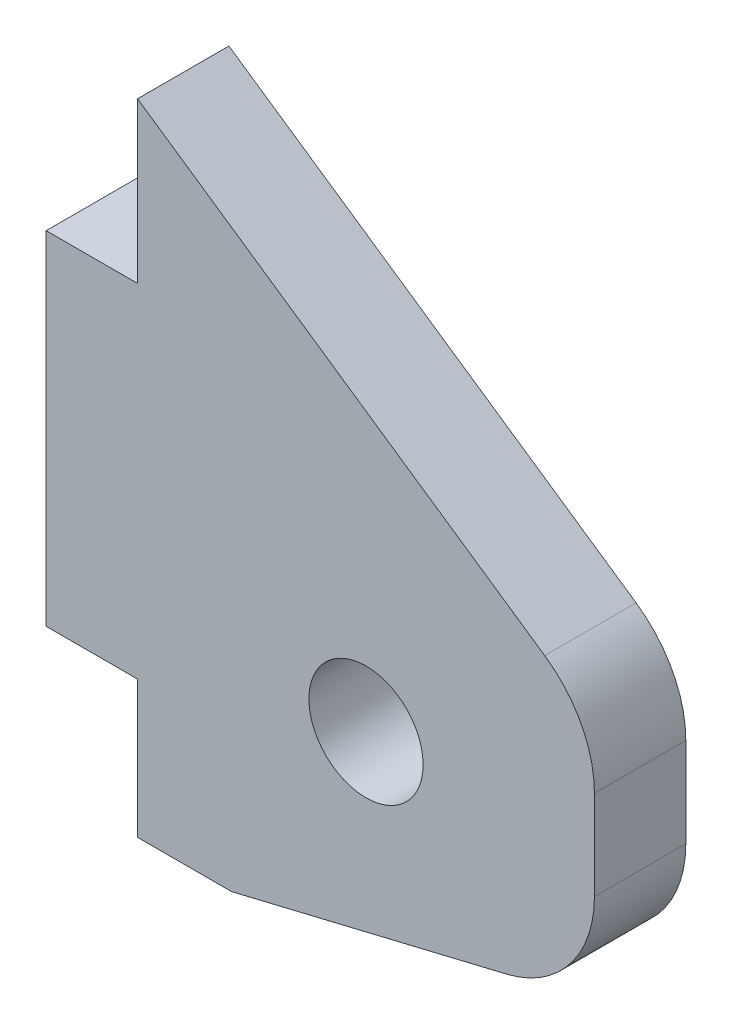
from build123d import *

# Parameters (mm, degrees)
SKETCH_1_R      = 2.5
EXTRUDE_1_DEPTH = 4
FILLET_1_R      = 5


with BuildPart() as part:
    # ｽｹｯﾁ1 → ﾎﾞｽ - 押し出し1 (new body)
    with BuildSketch(Plane.XY):
        Polygon((0, 15), (0, 0), (4, 0), (4, -6), (8.110763801, -6), (24, -2.18322685), (24, 8.312378031), (4, 22), (4, 15), align=None)
        with Locations((14, 3)):
            Circle(SKETCH_1_R, mode=Mode.SUBTRACT)
    extrude(amount=EXTRUDE_1_DEPTH)

    # ﾌｨﾚｯﾄ1
    fillet_1_edges = [part.edges().sort_by_distance(p)[0] for p in [
        (24, -2.18322685, 2),
        (24, 8.312378031, 2),
    ]]
    fillet(fillet_1_edges, radius=FILLET_1_R)


solid = part.part
